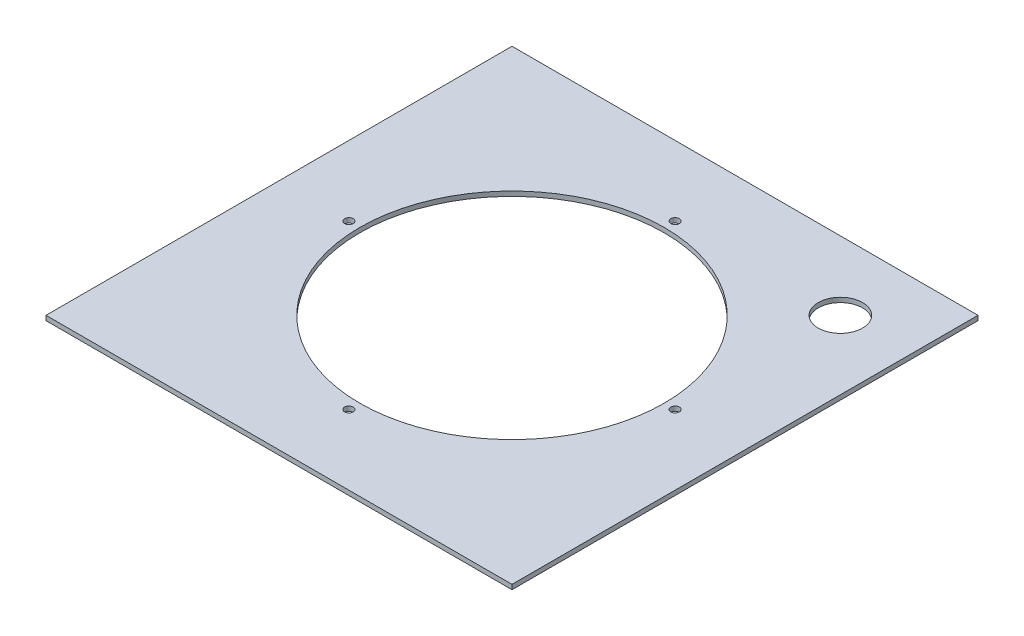
from build123d import *

# Parameters (mm, degrees)
SKETCH1_W           = 300
SKETCH1_H           = 300
BOSS_EXTRUDE1_DEPTH = 3
CUT_EXTRUDE1_REACH  = 5
SKETCH2_R           = 98
SKETCH2_R_2         = 14.255
SKETCH4_R           = 2.75
CUT_EXTRUDE3_DEPTH  = 4


with BuildPart() as part:
    # Sketch1 → Boss-Extrude1 (new body)
    with BuildSketch(Plane(origin=(0, 0, 0), x_dir=(1, 0, 0), z_dir=(0, 1, 0))):
        with Locations((150, -150)):
            Rectangle(SKETCH1_W, SKETCH1_H)
    extrude(amount=BOSS_EXTRUDE1_DEPTH)

    # Sketch2 → Cut-Extrude1 (cut, up to next)
    with BuildSketch(Plane(origin=(0, 3, 0), x_dir=(1, 0, 0), z_dir=(0, 1, 0)), mode=Mode.PRIVATE) as cut_extrude1_sk1:
        with Locations((150, -150)):
            Circle(SKETCH2_R)
    cut_extrude1_tool1 = extrude(cut_extrude1_sk1.sketch, amount=-CUT_EXTRUDE1_REACH, mode=Mode.PRIVATE) & part.part
    add(cut_extrude1_tool1.solids().sort_by_distance((150, 3, 150))[0], mode=Mode.SUBTRACT)
    # Sketch2 → Cut-Extrude1 (cut, up to next)
    with BuildSketch(Plane(origin=(0, 3, 0), x_dir=(1, 0, 0), z_dir=(0, 1, 0)), mode=Mode.PRIVATE) as cut_extrude1_sk2:
        with Locations((255.712463787, -44.287536213)):
            Circle(SKETCH2_R_2)
    cut_extrude1_tool2 = extrude(cut_extrude1_sk2.sketch, amount=-CUT_EXTRUDE1_REACH, mode=Mode.PRIVATE) & part.part
    add(cut_extrude1_tool2.solids().sort_by_distance((255.712464, 3, 44.287536))[0], mode=Mode.SUBTRACT)

    # Sketch4 → Cut-Extrude3 (cut, through all)
    with BuildSketch(Plane(origin=(0, 3, 0), x_dir=(1, 0, 0), z_dir=(0, 1, 0))):
        with Locations((45, -150)):
            Circle(SKETCH4_R)
        with Locations((255, -150)):
            Circle(SKETCH4_R)
        with Locations((150, -255)):
            Circle(SKETCH4_R)
        with Locations((150, -45)):
            Circle(SKETCH4_R)
    extrude(amount=-CUT_EXTRUDE3_DEPTH, mode=Mode.SUBTRACT)


solid = part.part
